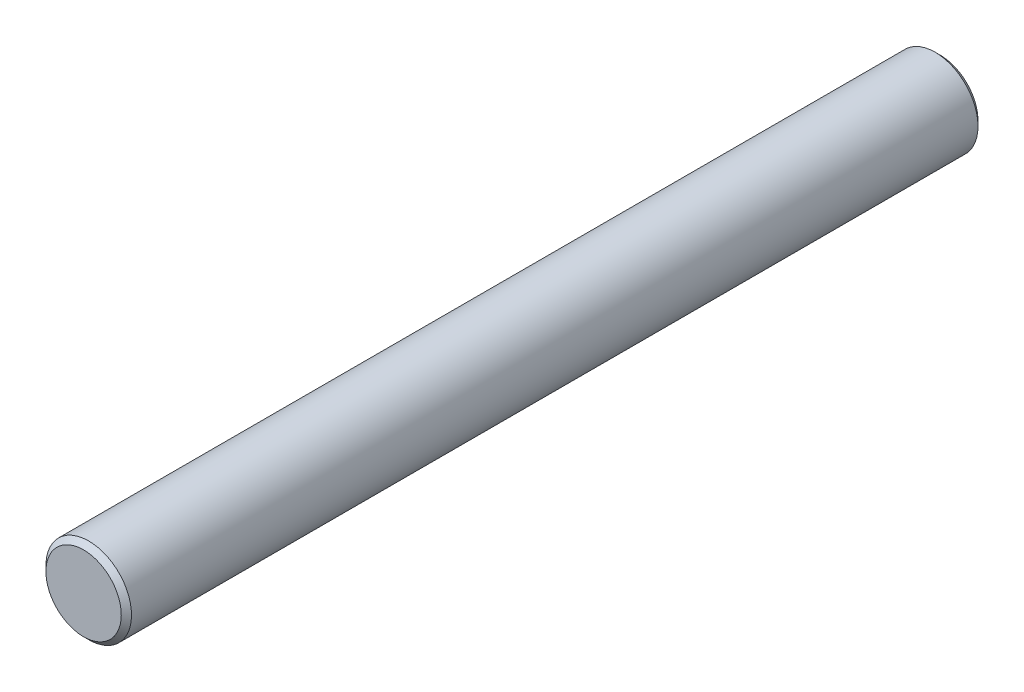
from build123d import *

# Parameters (mm, degrees)
SKETCH2_R           = 3.175
BOSS_EXTRUDE1_DEPTH = 62.81
SKETCH3_R           = 3.175
BOSS_EXTRUDE2_DEPTH = 0.38
BOSS_EXTRUDE2_TAPER = 45
SKETCH4_R           = 3.175
BOSS_EXTRUDE3_DEPTH = 0.38
BOSS_EXTRUDE3_TAPER = 45


with BuildPart() as part:
    # Sketch2 → Boss-Extrude1 (new body)
    with BuildSketch(Plane.XY):
        Circle(SKETCH2_R)
    extrude(amount=-BOSS_EXTRUDE1_DEPTH)

    # Sketch3 → Boss-Extrude2 (add)
    with BuildSketch(Plane.XY):
        Circle(SKETCH3_R)
    extrude(amount=BOSS_EXTRUDE2_DEPTH, taper=BOSS_EXTRUDE2_TAPER)

    # Sketch4 → Boss-Extrude3 (add)
    with BuildSketch(Plane(origin=(0, 0, -62.81), x_dir=(-1, 0, 0), z_dir=(0, 0, -1))):
        Circle(SKETCH4_R)
    extrude(amount=BOSS_EXTRUDE3_DEPTH, taper=BOSS_EXTRUDE3_TAPER)


solid = part.part
